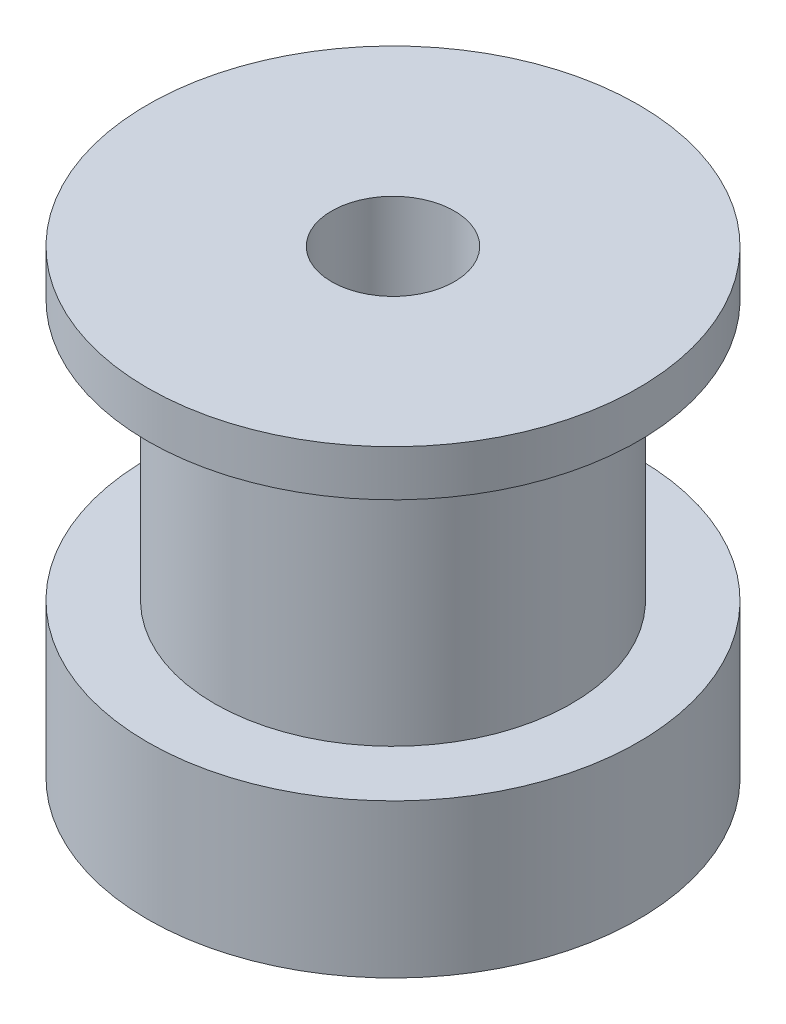
from build123d import *

# Parameters (mm, degrees)
CROQUIS1_R              = 8
CROQUIS1_R_2            = 2
SALIENTE_EXTRUIR1_DEPTH = 5
CROQUIS1_3_R            = 5.82
CROQUIS1_3_R_2          = 2
SALIENTE_EXTRUIR2_DEPTH = 13.5
CROQUIS2_R              = 8
CROQUIS2_R_2            = 2
SALIENTE_EXTRUIR7_DEPTH = 1.5
CORTAR_EXTRUIR1_REACH   = 20.788
CROQUIS3_R              = 2


with BuildPart() as part:
    # Croquis1 → Saliente-Extruir1 (new body)
    with BuildSketch(Plane(origin=(0, 0, 0), x_dir=(1, 0, 0), z_dir=(0, 1, 0))):
        Circle(CROQUIS1_R)
        Circle(CROQUIS1_R_2, mode=Mode.SUBTRACT)
    extrude(amount=SALIENTE_EXTRUIR1_DEPTH)

    # Croquis1_3 → Saliente-Extruir2 (add)
    with BuildSketch(Plane(origin=(0, 0, 0), x_dir=(1, 0, 0), z_dir=(0, 1, 0))):
        Circle(CROQUIS1_3_R)
        Circle(CROQUIS1_3_R_2, mode=Mode.SUBTRACT)
    extrude(amount=SALIENTE_EXTRUIR2_DEPTH)

    # Croquis2 → Saliente-Extruir7 (add)
    with BuildSketch(Plane(origin=(0, 13.5, 0), x_dir=(1, 0, 0), z_dir=(0, 1, 0))):
        Circle(CROQUIS2_R)
        Circle(CROQUIS2_R_2, mode=Mode.SUBTRACT)
    extrude(amount=SALIENTE_EXTRUIR7_DEPTH)

    # Croquis3 → Cortar-Extruir1 (cut, up to next)
    with BuildSketch(Plane(origin=(0, 0, 0), x_dir=(0, 0, -1), z_dir=(1, 0, 0)), mode=Mode.PRIVATE) as cortar_extruir1_sk1:
        with Locations((0, 2.5)):
            Circle(CROQUIS3_R)
    cortar_extruir1_tool1 = extrude(cortar_extruir1_sk1.sketch, amount=-CORTAR_EXTRUIR1_REACH, mode=Mode.PRIVATE) & part.part
    add(cortar_extruir1_tool1.solids().sort_by_distance((0, 2.5, 0))[0], mode=Mode.SUBTRACT)


solid = part.part
